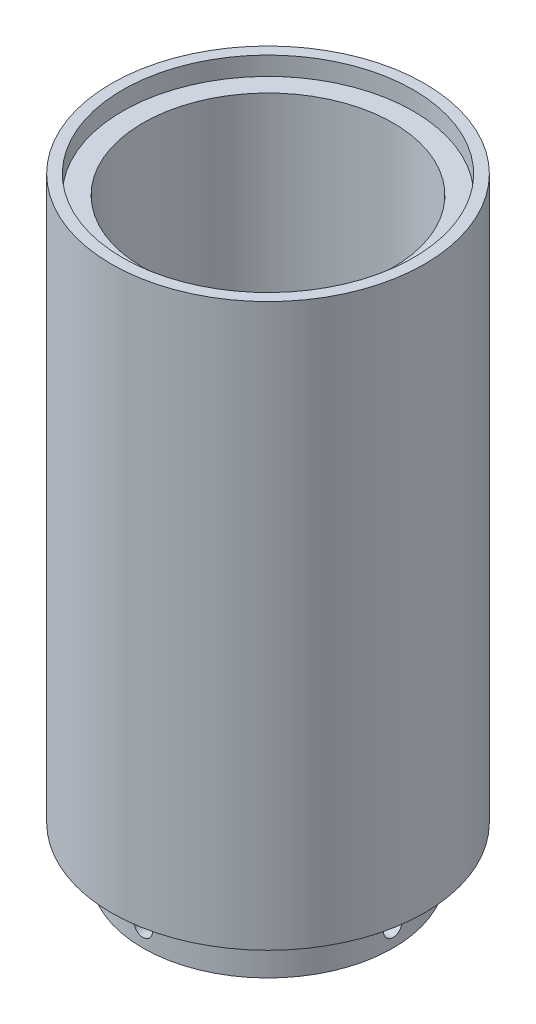
from build123d import *

# Parameters (mm, degrees)
SKETCH1_R               = 33.85
BOSS_EXTRUDE1_DEPTH     = 12.5
SKETCH2_R               = 2.5
CUT_EXTRUDE1_DEPTH      = 34.85
CUT_EXTRUDE1_DEPTH_BACK = 34.85
SKETCH3_R               = 2.5
CUT_EXTRUDE2_DEPTH      = 34.8500001
CUT_EXTRUDE2_DEPTH_BACK = 34.8500001
SKETCH4_R               = 42.35
BOSS_EXTRUDE2_DEPTH     = 2
SKETCH5_R               = 42.35
SKETCH5_R_2             = 33.85
BOSS_EXTRUDE3_DEPTH     = 150
SKETCH6_R               = 39.35
CUT_EXTRUDE3_DEPTH      = 5


with BuildPart() as part:
    # Sketch1 → Boss-Extrude1 (new body)
    with BuildSketch(Plane(origin=(0, 0, 0), x_dir=(1, 0, 0), z_dir=(0, 1, 0))):
        Circle(SKETCH1_R)
    extrude(amount=BOSS_EXTRUDE1_DEPTH)

    # Sketch2 → Cut-Extrude1 (cut, two sides)
    with BuildSketch(Plane(origin=(0, 0, 0), x_dir=(0, 0, -1), z_dir=(1, 0, 0))) as cut_extrude1_sk:
        with Locations((0, 5)):
            Circle(SKETCH2_R)
    extrude(amount=CUT_EXTRUDE1_DEPTH, mode=Mode.SUBTRACT)
    extrude(cut_extrude1_sk.sketch, amount=-CUT_EXTRUDE1_DEPTH_BACK, mode=Mode.SUBTRACT)

    # Sketch3 → Cut-Extrude2 (cut, two sides)
    with BuildSketch(Plane.XY) as cut_extrude2_sk:
        with Locations((0, 5)):
            Circle(SKETCH3_R)
    extrude(amount=CUT_EXTRUDE2_DEPTH, mode=Mode.SUBTRACT)
    extrude(cut_extrude2_sk.sketch, amount=-CUT_EXTRUDE2_DEPTH_BACK, mode=Mode.SUBTRACT)

    # Sketch4 → Boss-Extrude2 (add)
    with BuildSketch(Plane(origin=(0, 12.5, 0), x_dir=(1, 0, 0), z_dir=(0, 1, 0))):
        Circle(SKETCH4_R)
    extrude(amount=BOSS_EXTRUDE2_DEPTH)

    # Sketch5 → Boss-Extrude3 (add)
    with BuildSketch(Plane(origin=(0, 14.5, 0), x_dir=(1, 0, 0), z_dir=(0, 1, 0))):
        Circle(SKETCH5_R)
        Circle(SKETCH5_R_2, mode=Mode.SUBTRACT)
    extrude(amount=BOSS_EXTRUDE3_DEPTH)

    # Sketch6 → Cut-Extrude3 (cut)
    with BuildSketch(Plane(origin=(0, 164.5, 0), x_dir=(1, 0, 0), z_dir=(0, 1, 0))):
        Circle(SKETCH6_R)
    extrude(amount=-CUT_EXTRUDE3_DEPTH, mode=Mode.SUBTRACT)


solid = part.part
